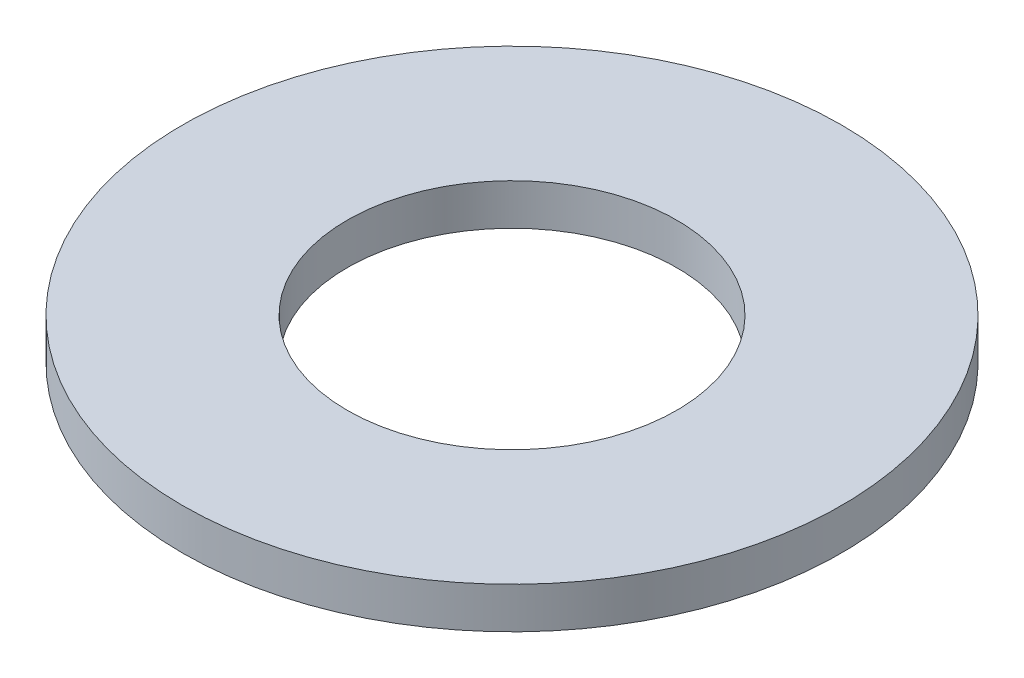
from build123d import *

# Parameters (mm, degrees)
SKETCH_1_R      = 4
SKETCH_1_R_2    = 2
EXTRUDE_1_DEPTH = 0.5


with BuildPart() as part:
    # 草图1 → 凸台-拉伸1 (new body)
    with BuildSketch(Plane(origin=(0, 0, 0), x_dir=(1, 0, 0), z_dir=(0, 1, 0))):
        Circle(SKETCH_1_R)
        Circle(SKETCH_1_R_2, mode=Mode.SUBTRACT)
    extrude(amount=EXTRUDE_1_DEPTH)


solid = part.part
